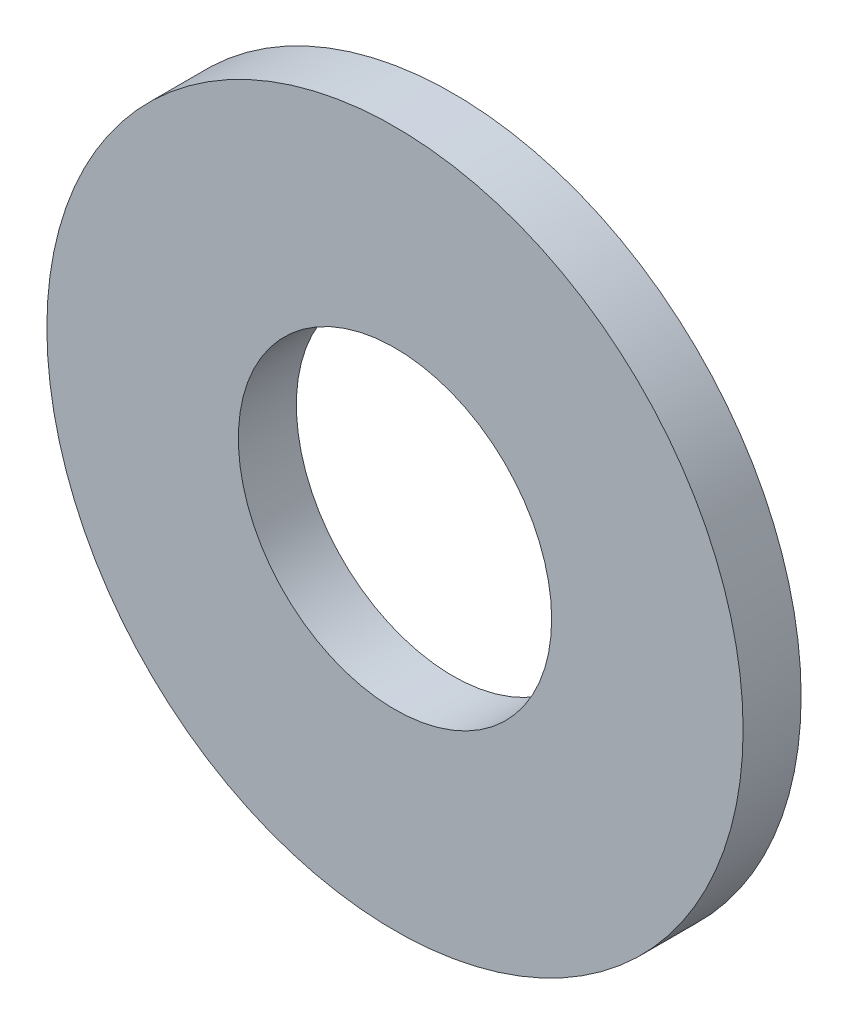
from build123d import *

# Parameters (mm, degrees)
SKETCH_1_R      = 3
SKETCH_1_R_2    = 1.35
EXTRUDE_1_DEPTH = 0.5


with BuildPart() as part:
    # Эскиз1 → Бобышка-Вытянуть1 (new body)
    with BuildSketch(Plane.XY):
        Circle(SKETCH_1_R)
        Circle(SKETCH_1_R_2, mode=Mode.SUBTRACT)
    extrude(amount=EXTRUDE_1_DEPTH)


solid = part.part
